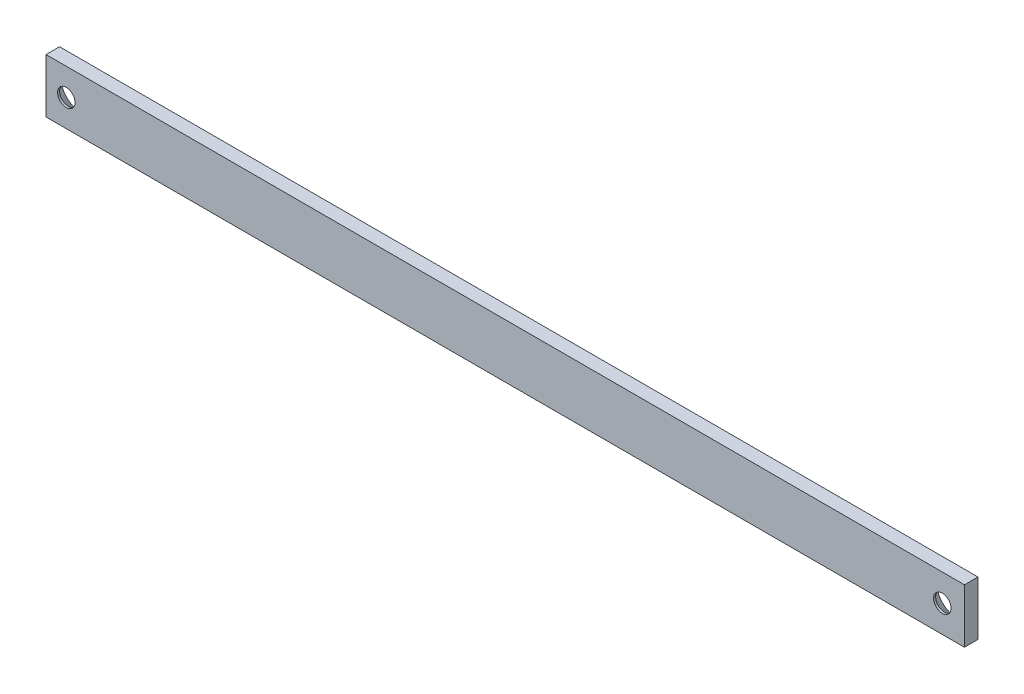
from build123d import *

# Parameters (mm, degrees)
SKETCH3_W                                    = 431.251100871
SKETCH3_H                                    = 25.4
EXTRUDE1_DEPTH                               = 6.35
CSK_FOR_5_16_FLAT_HEAD_SOCKET_CAP_SC_2_COUNT = 2
CSK_FOR_5_16_FLAT_HEAD_SOCKET_CAP_SC_2_PITCH = 411.312205256


with BuildPart() as part:
    # Sketch3 → Extrude1 (new body)
    with BuildSketch(Plane(origin=(0, 0, 0), x_dir=(-1, 0, 0), z_dir=(0, 0, -1))):
        with Locations((-0.444447807, -41.102479446)):
            Rectangle(SKETCH3_W, SKETCH3_H)
    extrude(amount=EXTRUDE1_DEPTH)

    # Sketch4 → CSK for 5/16 Flat Head Socket Cap Screw1 (revolve, cut)
    with BuildSketch(Plane(origin=(205.656102628, -41.102479446, -6.35), x_dir=(0, 1, 0), z_dir=(1, 0, 0))):
        Polygon((0, 0), (0, 6.35), (4.1021, 6.35), (4.1021, 5.373016172), (8.7727917, 0), align=None)
    csk_for_5_16_flat_head_socket_cap_screw1 = revolve(axis=Axis((205.656102628, -41.102479446, -12.7), (0, 0, 1)), mode=Mode.SUBTRACT)

    # CSK for 5_16 Flat Head Socket Cap Sc 2: CSK for 5/16 Flat Head Socket Cap Screw1 ×2
    with Locations(*[(-i * CSK_FOR_5_16_FLAT_HEAD_SOCKET_CAP_SC_2_PITCH, 0, 0) for i in range(1, CSK_FOR_5_16_FLAT_HEAD_SOCKET_CAP_SC_2_COUNT)]):
        add(csk_for_5_16_flat_head_socket_cap_screw1, mode=Mode.SUBTRACT)


solid = part.part
